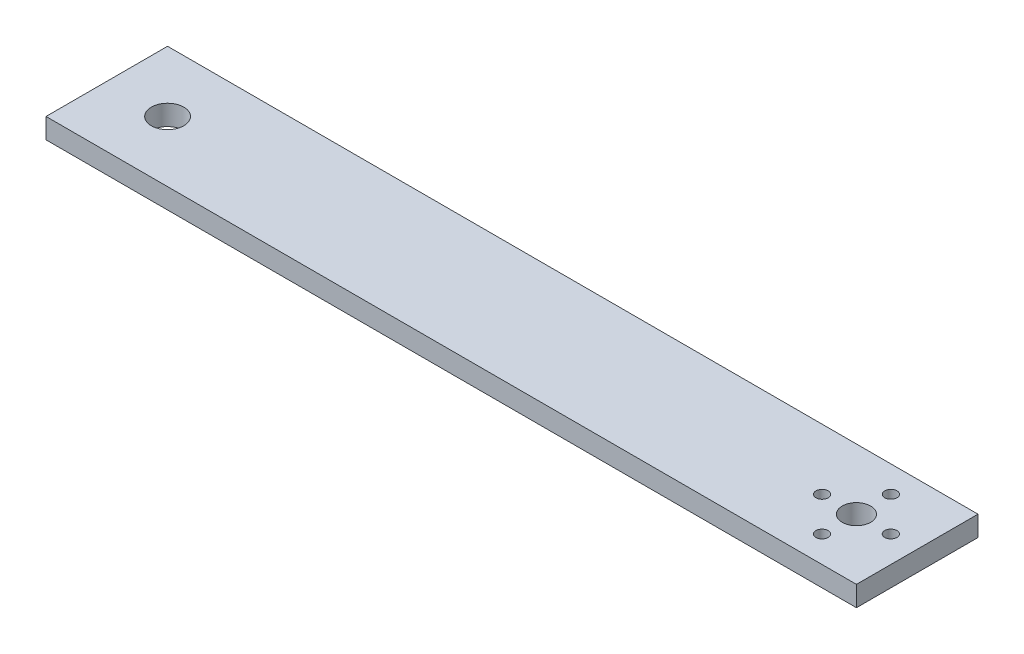
from build123d import *

# Parameters (mm, degrees)
SKETCH1_W           = 200
SKETCH1_H           = 30
BOSS_EXTRUDE1_DEPTH = 5
SKETCH2_R           = 4
SKETCH2_R_2         = 3.5
SKETCH2_R_3         = 1.5
CUT_EXTRUDE1_DEPTH  = 5


with BuildPart() as part:
    # Sketch1 → Boss-Extrude1 (new body)
    with BuildSketch(Plane(origin=(0, 0, 0), x_dir=(1, 0, 0), z_dir=(0, 1, 0))):
        with Locations((100, 15)):
            Rectangle(SKETCH1_W, SKETCH1_H)
    extrude(amount=BOSS_EXTRUDE1_DEPTH)

    # Sketch2 → Cut-Extrude1 (cut)
    with BuildSketch(Plane(origin=(0, 5, 0), x_dir=(1, 0, 0), z_dir=(0, 1, 0))):
        with Locations((15, 15)):
            Circle(SKETCH2_R)
        with Locations((185, 15)):
            Circle(SKETCH2_R_2)
        with Locations((185, 23.5)):
            Circle(SKETCH2_R_3)
        with Locations((193.479139517, 15)):
            Circle(SKETCH2_R_3)
        with Locations((176.520860483, 15)):
            Circle(SKETCH2_R_3)
        with Locations((185, 6.5)):
            Circle(SKETCH2_R_3)
    extrude(amount=-CUT_EXTRUDE1_DEPTH, mode=Mode.SUBTRACT)


solid = part.part
